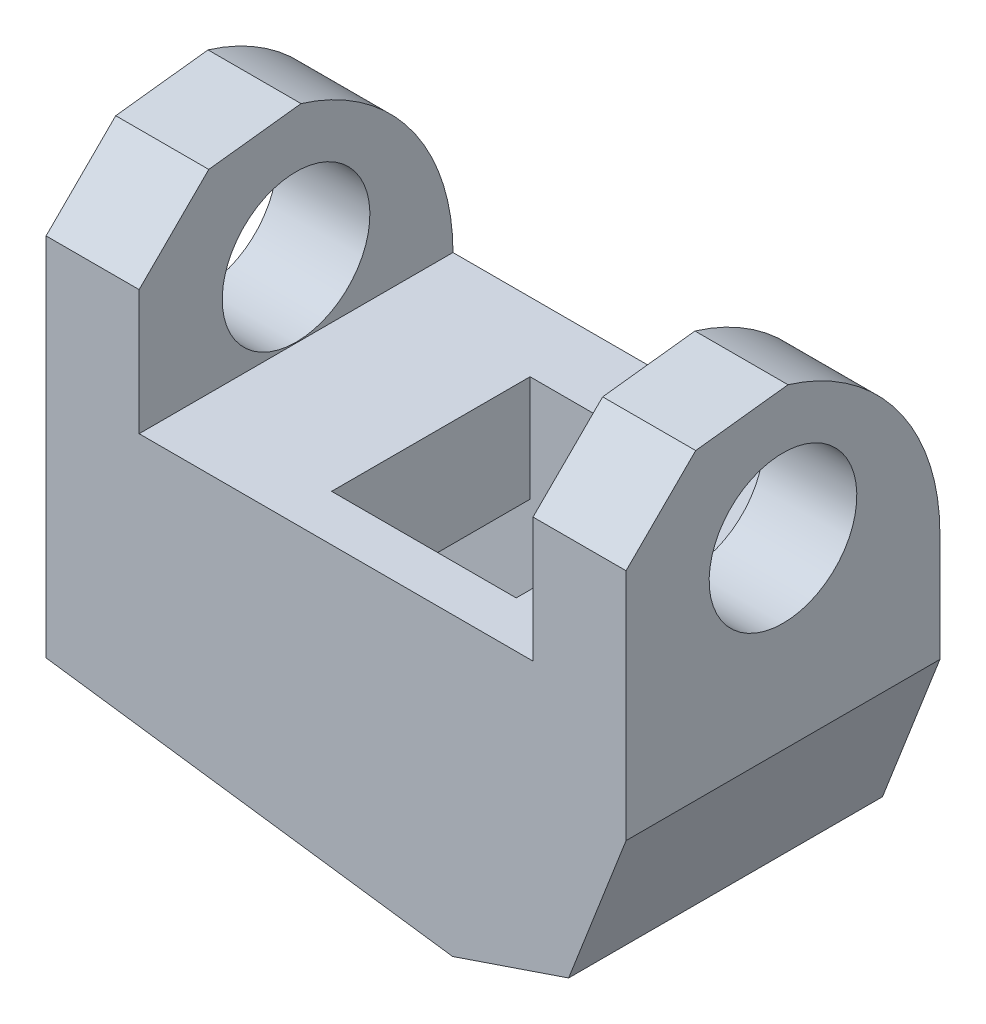
from build123d import *

# Parameters (mm, degrees)
BOSS_EXTRUDE1_DEPTH = 17
CUT_EXTRUDE1_DEPTH  = 31
SKETCH3_W           = 12.47
SKETCH3_H           = 10.75
CUT_EXTRUDE2_REACH  = 37.239
SKETCH6_W           = 10
SKETCH6_H           = 10.75
SKETCH7_R           = 4
CUT_EXTRUDE3_DEPTH  = 31


with BuildPart() as part:
    # Sketch1 → Boss-Extrude1 (new body)
    with BuildSketch(Plane.XY):
        Polygon((0, 0), (0, 11.1), (5.04, 11.1), (5.04, -5.9), (1.928970145, -13.9), (-4.358645915, -16.03435805), (-26.37555014, -13.036971131), (-26.37555014, 11.1), (-21.33555014, 11.1), (-21.33555014, 0), align=None)
    extrude(amount=BOSS_EXTRUDE1_DEPTH)

    # Sketch2 → Cut-Extrude1 (cut, symmetric)
    with BuildSketch(Plane.ZY):
        Polygon((8.228054067, 11.1), (17, 11.1), (17, 12.88110255), (0, 12.88110255), (0, 11.1), align=None)
        with BuildLine():
            ThreePointArc((0, 0), (2.28131811, 6.908525055), (8.228054067, 11.1))
            Line((8.228054067, 11.1), (0, 11.1))
            Line((0, 11.1), (0, 0))
        make_face()
        Polygon((13.228054067, 10.512247596), (17, 6.76), (17, 11.1), (8.228054067, 11.1), align=None)
    extrude(amount=CUT_EXTRUDE1_DEPTH, both=True, mode=Mode.SUBTRACT)

    # Cut-Sweep1: sweep along a path in Sketch5
    with BuildLine(Plane.XY.offset(7)) as cut_sweep1_path:
        Line((-9.535960256, -15.329517164), (-6.500512954, -6.687083497))
    # Sketch3 → Cut-Sweep1 (sweep, cut)
    with BuildSketch(Plane(origin=(-2.222513014, -16.325171724, 0), x_dir=(-0.990859776111597, 0.13489590091650622, 0), z_dir=(-0.13489590091650622, -0.990859776111597, 0))):
        with Locations((12.41083774, -9.115)):
            Rectangle(SKETCH3_W, SKETCH3_H)
    sweep(path=cut_sweep1_path.line, mode=Mode.SUBTRACT)

    # Cut-Extrude2: up to this plane
    cut_extrude2_end = Plane(origin=(-8.680240671, -16.455383538, 3.74), z_dir=(-0.943497125175066, 0.33138070973788714, 0))
    # Sketch6 → Cut-Extrude2 (cut, up to the surface)
    with BuildSketch(Plane(origin=(0, 0, 0), x_dir=(1, 0, 0), z_dir=(0, 1, 0)), mode=Mode.PRIVATE) as cut_extrude2_sk1:
        with Locations((-8.42, -9.115)):
            Rectangle(SKETCH6_W, SKETCH6_H)
    cut_extrude2_tool1 = split(extrude(cut_extrude2_sk1.sketch, amount=-CUT_EXTRUDE2_REACH, mode=Mode.PRIVATE), bisect_by=cut_extrude2_end, keep=Keep.BOTH, mode=Mode.PRIVATE)
    add(cut_extrude2_tool1.solids().sort_by_distance((-8.42, 0, 9.115))[0], mode=Mode.SUBTRACT)

    # Sketch7 → Cut-Extrude3 (cut, symmetric)
    with BuildSketch(Plane.ZY.offset(10.66777507)):
        with Locations(Location((8.5, 4.041620851, 0), (0, 0, 270))):
            Circle(SKETCH7_R)
    extrude(amount=CUT_EXTRUDE3_DEPTH, both=True, mode=Mode.SUBTRACT)


solid = part.part
